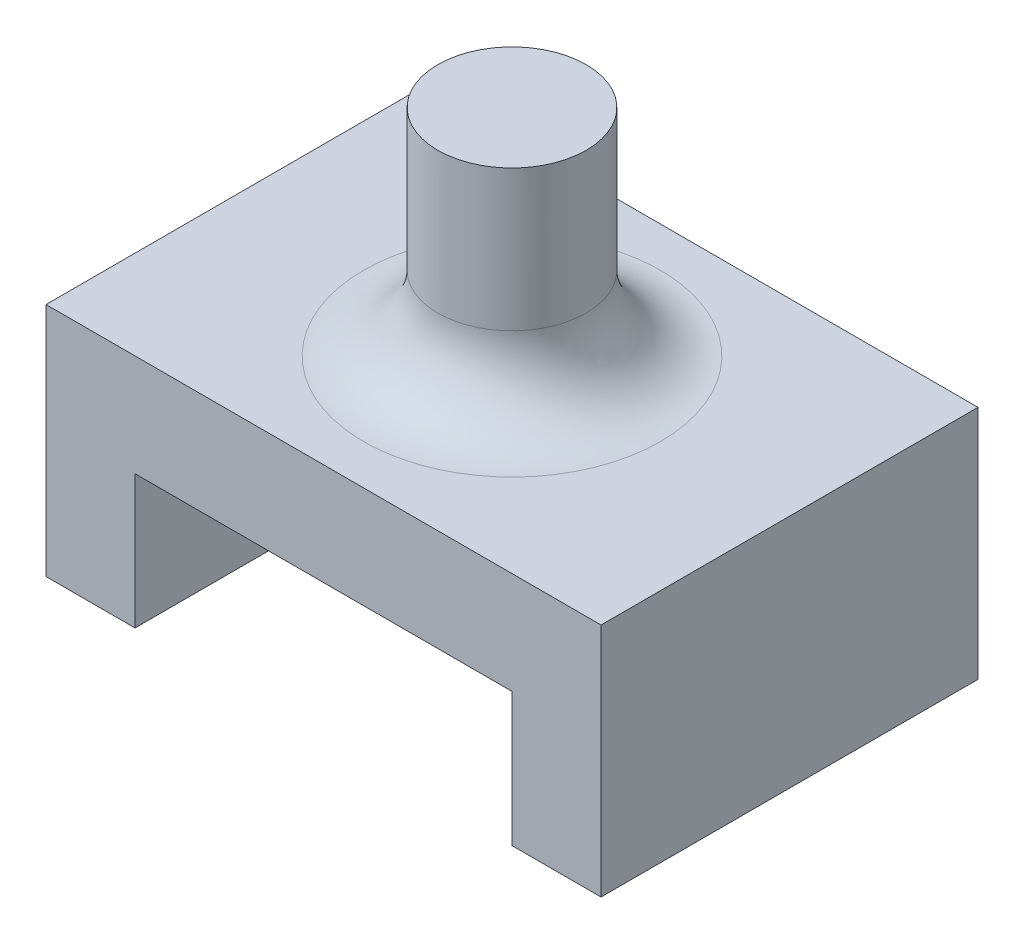
from build123d import *

# Parameters (mm, degrees)
BOSS_EXTRUDE1_DEPTH = 25.4
SKETCH2_R           = 5
BOSS_EXTRUDE2_DEPTH = 14.5
FILLET1_R           = 5


with BuildPart() as part:
    # Sketch1 → Boss-Extrude1 (new body)
    with BuildSketch(Plane.XY):
        Polygon((-10.189534884, 0), (-10.189534884, 9), (15.210465116, 9), (15.210465116, 0), (21.210465116, 0), (21.210465116, 15.875), (-16.189534884, 15.875), (-16.189534884, 0), align=None)
    extrude(amount=BOSS_EXTRUDE1_DEPTH)

    # Sketch2 → Boss-Extrude2 (add)
    with BuildSketch(Plane(origin=(0, 15.875, 0), x_dir=(1, 0, 0), z_dir=(0, 1, 0))):
        with Locations((2.510465116, -12.7)):
            Circle(SKETCH2_R)
    extrude(amount=BOSS_EXTRUDE2_DEPTH)

    # Fillet1
    fillet1_edges = [part.edges().sort_by_distance(p)[0] for p in [
        (-2.489534884, 15.875, 12.7),
    ]]
    fillet(fillet1_edges, radius=FILLET1_R)


solid = part.part
